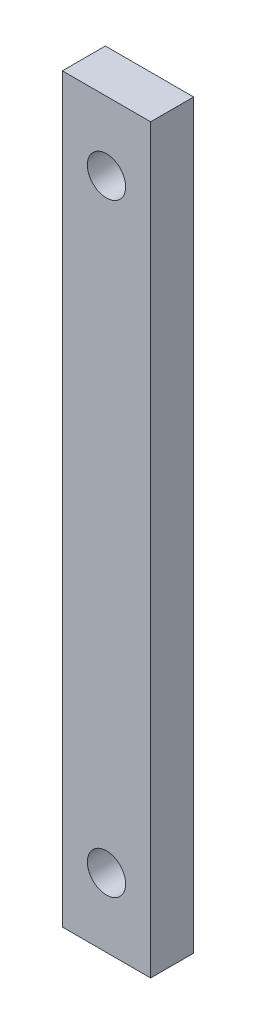
from build123d import *

# Parameters (mm, degrees)
SKETCH1_W           = 6.52
SKETCH1_H           = 54.77
BOSS_EXTRUDE1_DEPTH = 3.175
SKETCH2_R           = 1.415
CUT_EXTRUDE1_DEPTH  = 4.175


with BuildPart() as part:
    # Sketch1 → Boss-Extrude1 (new body)
    with BuildSketch(Plane.XY):
        Rectangle(SKETCH1_W, SKETCH1_H)
    extrude(amount=BOSS_EXTRUDE1_DEPTH)

    # Sketch2 → Cut-Extrude1 (cut, through all)
    with BuildSketch(Plane.XY.offset(3.175)):
        with Locations((0, 22.295)):
            Circle(SKETCH2_R)
        with Locations((0, -22.295)):
            Circle(SKETCH2_R)
    extrude(amount=-CUT_EXTRUDE1_DEPTH, mode=Mode.SUBTRACT)


solid = part.part
